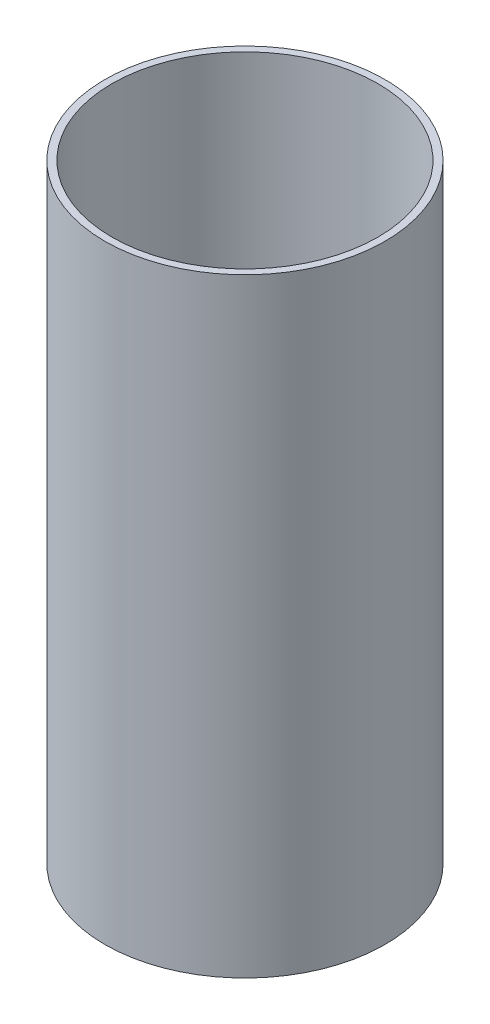
from build123d import *

# Parameters (mm, degrees)
SKETCH1_R           = 93.6625
SKETCH1_R_2         = 88.9
BOSS_EXTRUDE1_DEPTH = 203.581


with BuildPart() as part:
    # Sketch1 → Boss-Extrude1 (new body, symmetric)
    with BuildSketch(Plane(origin=(0, 0, 0), x_dir=(1, 0, 0), z_dir=(0, 1, 0))):
        Circle(SKETCH1_R)
        Circle(SKETCH1_R_2, mode=Mode.SUBTRACT)
    extrude(amount=BOSS_EXTRUDE1_DEPTH, both=True)


solid = part.part
